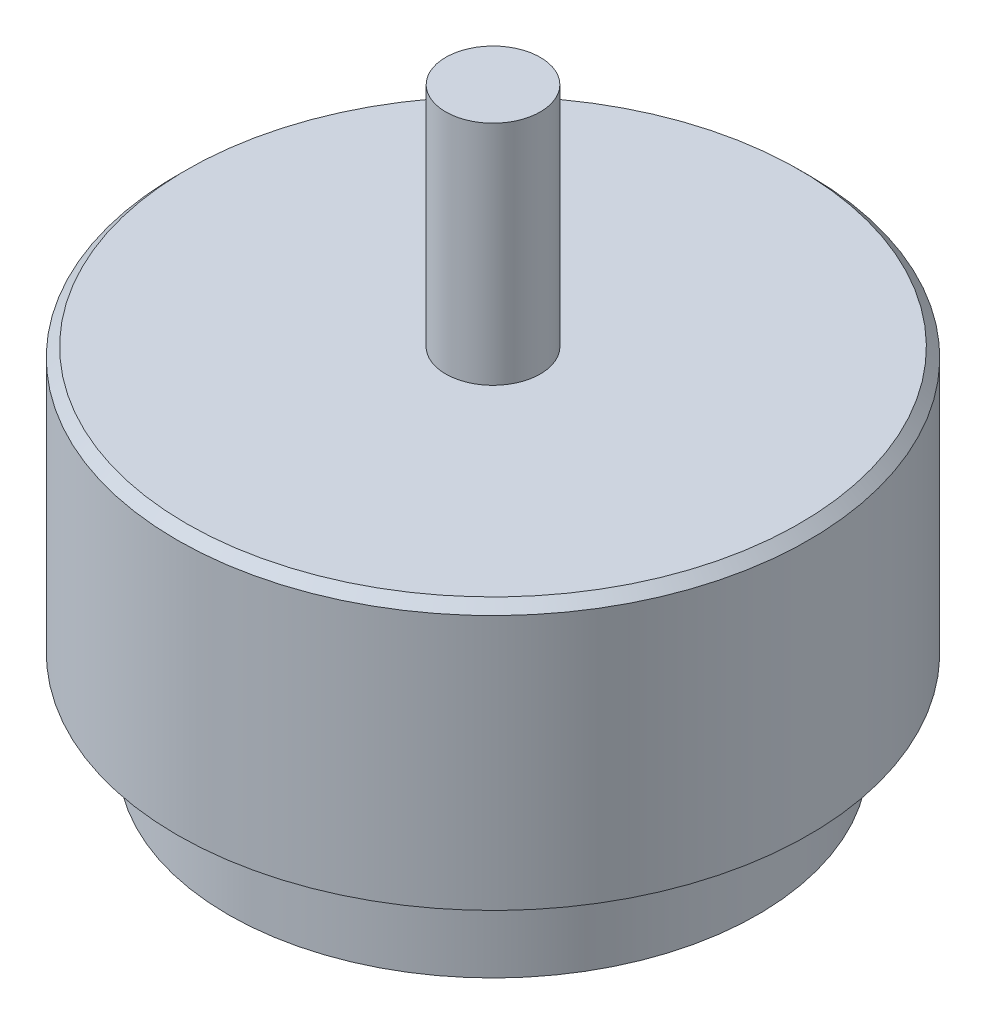
from build123d import *

# Parameters (mm, degrees)
SKETCH1_R           = 14
BOSS_EXTRUDE1_DEPTH = 5
SKETCH2_R           = 16.7
BOSS_EXTRUDE2_DEPTH = 14
SKETCH3_R           = 2.5
BOSS_EXTRUDE3_DEPTH = 12
CHAMFER1_SIZE       = 0.5
SKETCH4_R           = 7
CUT_EXTRUDE1_DEPTH  = 6


with BuildPart() as part:
    # Sketch1 → Boss-Extrude1 (new body)
    with BuildSketch(Plane(origin=(0, 0, 0), x_dir=(1, 0, 0), z_dir=(0, 1, 0))):
        Circle(SKETCH1_R)
    extrude(amount=BOSS_EXTRUDE1_DEPTH)

    # Sketch2 → Boss-Extrude2 (add)
    with BuildSketch(Plane(origin=(0, 5, 0), x_dir=(1, 0, 0), z_dir=(0, 1, 0))):
        Circle(SKETCH2_R)
    extrude(amount=BOSS_EXTRUDE2_DEPTH)

    # Sketch3 → Boss-Extrude3 (add)
    with BuildSketch(Plane(origin=(0, 19, 0), x_dir=(1, 0, 0), z_dir=(0, 1, 0))):
        Circle(SKETCH3_R)
    extrude(amount=BOSS_EXTRUDE3_DEPTH)

    # Chamfer1
    chamfer1_edges = [part.edges().sort_by_distance(p)[0] for p in [
        (-16.7, 19, 0),
    ]]
    chamfer(chamfer1_edges, length=CHAMFER1_SIZE)

    # Sketch4 → Cut-Extrude1 (cut)
    with BuildSketch(Plane.XZ):
        Circle(SKETCH4_R)
    extrude(amount=-CUT_EXTRUDE1_DEPTH, mode=Mode.SUBTRACT)


solid = part.part
